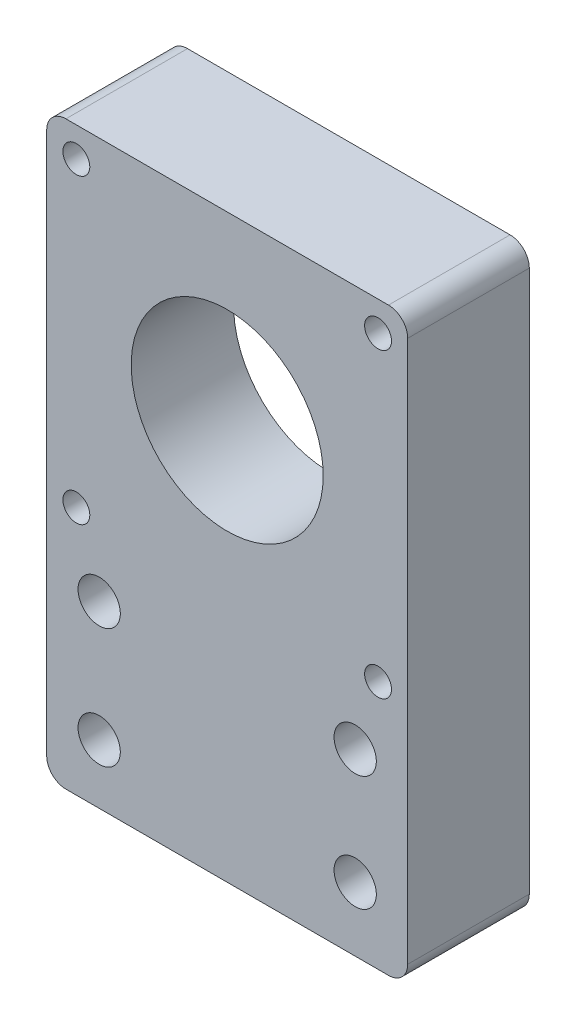
from build123d import *

# Parameters (mm, degrees)
SKETCH1_W               = 56.4
SKETCH1_H               = 56.4
BOSS_EXTRUDE1_DEPTH     = 19
SKETCH2_R               = 20.904355549
CUT_EXTRUDE2_DEPTH      = 20
SKETCH3_W               = 56.4
SKETCH3_H               = 34.3
BOSS_EXTRUDE2_DEPTH     = 19
FILLET1_R               = 3
TAP_DRILL_FOR_M5_TAP1_D = 4.2
M6_CLEARANCE_HOLE1_D    = 6.6
SKETCH8_R               = 20.904355549
SKETCH8_R_2             = 15
BOSS_EXTRUDE3_DEPTH     = 16


with BuildPart() as part:
    # Sketch1 → Boss-Extrude1 (new body)
    with BuildSketch(Plane.XY):
        with Locations((0, 25)):
            Rectangle(SKETCH1_W, SKETCH1_H)
    extrude(amount=BOSS_EXTRUDE1_DEPTH)

    # Sketch2 → Cut-Extrude2 (cut)
    with BuildSketch(Plane.XY.offset(19)):
        with Locations((0, 25)):
            Circle(SKETCH2_R)
    extrude(amount=-CUT_EXTRUDE2_DEPTH, mode=Mode.SUBTRACT)

    # Sketch3 → Boss-Extrude2 (add)
    with BuildSketch(Plane(origin=(0, 0, 0), x_dir=(-1, 0, 0), z_dir=(0, 0, -1))):
        with Locations((0, -20.35)):
            Rectangle(SKETCH3_W, SKETCH3_H)
    extrude(amount=-BOSS_EXTRUDE2_DEPTH)

    # Fillet1
    fillet1_edges = [part.edges().sort_by_distance(p)[0] for p in [
        (28.2, -37.5, 9.5),
        (-28.2, -37.5, 9.5),
        (28.2, 53.2, 9.5),
        (-28.2, 53.2, 9.5),
    ]]
    fillet(fillet1_edges, radius=FILLET1_R)

    # Tap Drill for M5 Tap1 (through all)
    with Locations(Plane(origin=(0, 0, 0), x_dir=(-1, 0, 0), z_dir=(0, 0, -1))):
        with Locations((-23.57, 48.57), (23.57, 48.57), (-23.57, 1.43), (23.57, 1.43)):
            Hole(TAP_DRILL_FOR_M5_TAP1_D / 2)

    # M6 Clearance Hole1 (through all)
    with Locations(Plane(origin=(0, 0, 0), x_dir=(-1, 0, 0), z_dir=(0, 0, -1))):
        with Locations((-20, -9.5), (-20, -27.5), (20, -28.237657735), (20, -9.5)):
            Hole(M6_CLEARANCE_HOLE1_D / 2)

    # Sketch8 → Boss-Extrude3 (add)
    with BuildSketch(Plane.XY.offset(19)):
        with Locations((0, 25)):
            Circle(SKETCH8_R)
        with Locations((0, 25)):
            Circle(SKETCH8_R_2, mode=Mode.SUBTRACT)
    extrude(amount=-BOSS_EXTRUDE3_DEPTH)


solid = part.part
